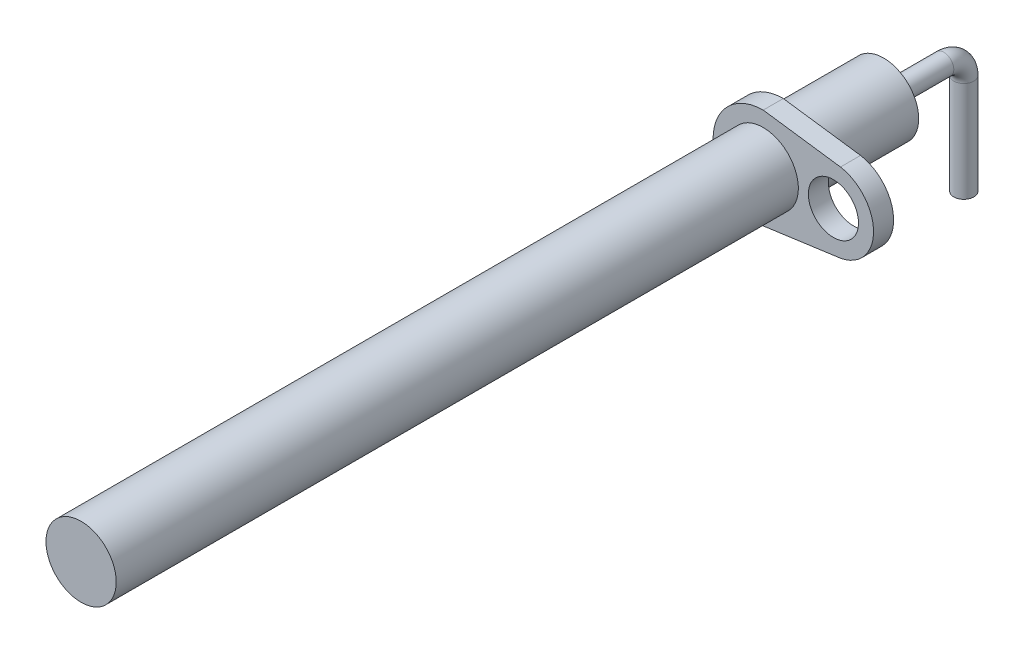
from build123d import *

# Parameters (mm, degrees)
SKETCH1_R           = 1.75
BOSS_EXTRUDE1_DEPTH = 40
SWEEP1_PROFILE_R    = 0.5
SKETCH16_R          = 1.25
BOSS_EXTRUDE2_DEPTH = 1


with BuildPart() as part:
    # Sketch1 → Boss-Extrude1 (new body)
    with BuildSketch(Plane.XY):
        Circle(SKETCH1_R)
    extrude(amount=BOSS_EXTRUDE1_DEPTH)

    # Sweep1: sweep along a curve in space
    with BuildLine() as sweep1_path:
        Line((0, 0, 0), (0, 0, -3))
        ThreePointArc((0, 0, -3), (0, -0.292893219, -3.707106781), (0, -1, -4))
        Line((0, -1, -4), (0, -6, -4))
    # Sweep1 profile (on start of the path) → Sweep1 (sweep)
    with BuildSketch(Plane(origin=(0, 0, 0), x_dir=(-1, 0, 0), z_dir=(0, 0, -1))):
        Circle(SWEEP1_PROFILE_R)
    sweep(path=sweep1_path.line)

    # Sketch16 → Boss-Extrude2 (add)
    with BuildSketch(Plane(origin=(0, 0, 6), x_dir=(-1, 0, 0), z_dir=(0, 0, -1))):
        with BuildLine():
            Line((-3.851561771, 1.968858634), (0, 2.5))
            ThreePointArc((0, 2.5), (2.5, 0), (0, -2.5))
            Line((0, -2.5), (-3.851561771, -1.968858634))
            ThreePointArc((-3.851561771, -1.968858634), (-5.5, 0), (-3.851561771, 1.968858634))
        make_face()
        with Locations((-3.5, 0)):
            Circle(SKETCH16_R, mode=Mode.SUBTRACT)
    extrude(amount=BOSS_EXTRUDE2_DEPTH)


solid = part.part
